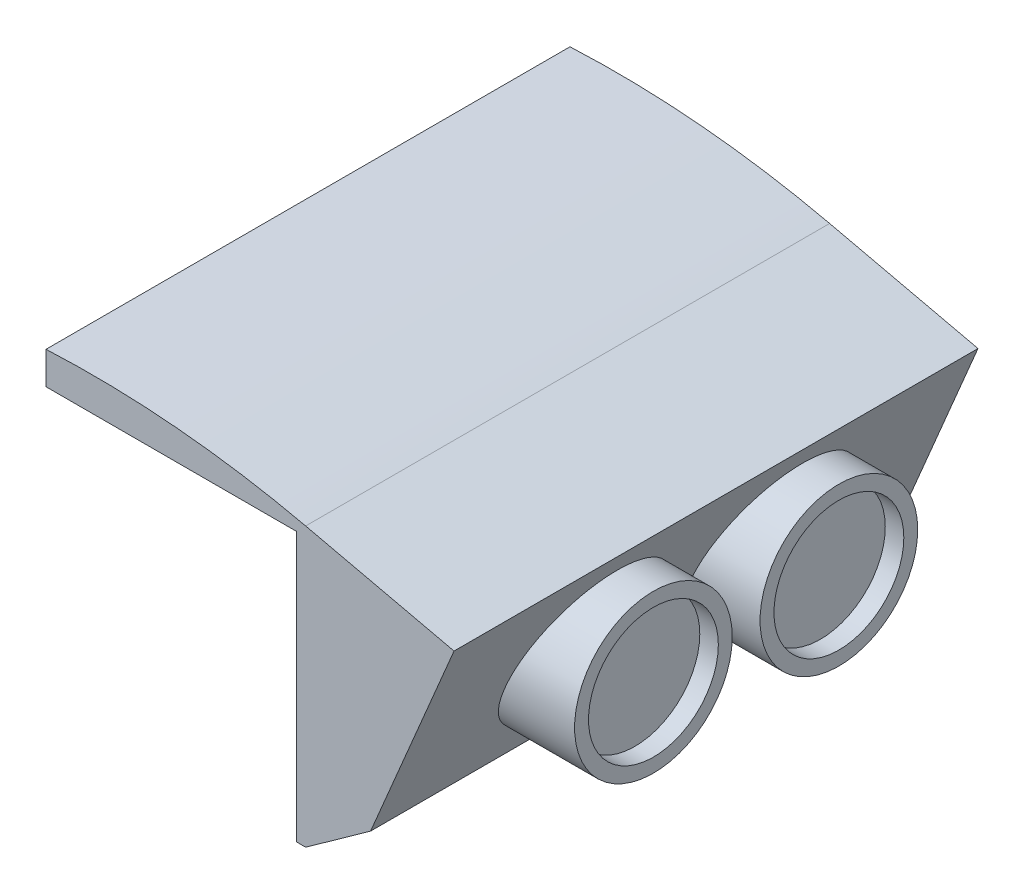
from build123d import *

# Parameters (mm, degrees)
SKETCH1_W           = 28
SKETCH1_H           = 56.5
BOSS_EXTRUDE1_DEPTH = 30
CUT_EXTRUDE2_DEPTH  = 56.5
SHELL1_T            = -1
BOSS_EXTRUDE3_DEPTH = 2.5
SKETCH4_R           = 0.35
CUT_EXTRUDE1_DEPTH  = 5
BOSS_EXTRUDE4_DEPTH = 56.5
BOSS_EXTRUDE5_START = -11.087816
SKETCH7_R           = 8.5
BOSS_EXTRUDE5_DEPTH = 11.087816
SKETCH8_R           = 7
CUT_EXTRUDE3_DEPTH  = 2
LPATTERN1_COUNT     = 2
LPATTERN1_PITCH     = 20


with BuildPart() as part:
    # Sketch1 → Boss-Extrude1 (new body)
    with BuildSketch(Plane(origin=(0, 0, 0), x_dir=(1, 0, 0), z_dir=(0, 1, 0))):
        Rectangle(SKETCH1_W, SKETCH1_H)
    extrude(amount=-BOSS_EXTRUDE1_DEPTH)

    # Sketch5 → Cut-Extrude2 (cut)
    with BuildSketch(Plane(origin=(0, 0, -28.25), x_dir=(-1, 0, 0), z_dir=(0, 0, -1))):
        with BuildLine():
            Line((-1, -30), (-1, -26))
            ThreePointArc((-1, -26), (3.188611699, -13.752551286), (14, -6.635083269))
            Line((14, -6.635083269), (14, -30))
            Line((14, -30), (-1, -30))
        make_face()
    extrude(amount=-CUT_EXTRUDE2_DEPTH, mode=Mode.SUBTRACT)

    # Shell1
    shell1_openings = [part.faces().sort_by_distance(p)[0] for p in [
        (7.5, -30, 0),
        (0.885231383, -15.011682153, 28.25),
        (-14, -3.317541634, 0),
        (-4.84430585, -15.03504646, 0),
        (1, -28, 0),
    ]]
    offset(amount=SHELL1_T, openings=shell1_openings, kind=Kind.INTERSECTION)

    # Sketch3 → Boss-Extrude3 (add, symmetric)
    with BuildSketch(Plane.XY.offset(-20)):
        with BuildLine():
            Line((-14, -1), (-15, -1))
            ThreePointArc((-15, -1), (-15.5, -1.5), (-15, -2))
            Line((-15, -2), (-14, -2))
            Line((-14, -2), (-12.5, -1))
            Line((-12.5, -1), (-14, -1))
        make_face()
    boss_extrude3 = extrude(amount=BOSS_EXTRUDE3_DEPTH, both=True)

    # Sketch4 → Cut-Extrude1 (cut)
    with BuildSketch(Plane(origin=(0, 0, -22.5), x_dir=(-1, 0, 0), z_dir=(0, 0, -1))):
        with Locations((15, -1.5)):
            Circle(SKETCH4_R)
    cut_extrude1 = extrude(amount=-CUT_EXTRUDE1_DEPTH, mode=Mode.SUBTRACT)

    # Mirror1: Boss-Extrude3, Cut-Extrude1 across plane
    add(boss_extrude3.mirror(Plane.XY))
    add(cut_extrude1.mirror(Plane.XY), mode=Mode.SUBTRACT)

    # Sketch6 → Boss-Extrude4 (add)
    with BuildSketch(Plane(origin=(0, 0, -28.25), x_dir=(-1, 0, 0), z_dir=(0, 0, -1))):
        Polygon((-30, -3.677832944), (-21, -25), (-14, -30), (-14, 0), align=None)
        with BuildLine():
            Line((14, 0), (14, 2.5))
            ThreePointArc((14, 2.5), (-0.085690207, 2.209730318), (-14, 0))
            Line((-14, 0), (14, 0))
        make_face()
    extrude(amount=-BOSS_EXTRUDE4_DEPTH)

    # Sketch7 → Boss-Extrude5 (add)
    with BuildSketch(Plane(origin=(33, 0, 0), x_dir=(0, 0, -1), z_dir=(1, 0, 0)).offset(BOSS_EXTRUDE5_START)):
        with Locations((10.25, -14.338916472)):
            Circle(SKETCH7_R)
    boss_extrude5 = extrude(amount=BOSS_EXTRUDE5_DEPTH)

    # Sketch8 → Cut-Extrude3 (cut)
    with BuildSketch(Plane(origin=(33, 0, 0), x_dir=(0, 0, -1), z_dir=(1, 0, 0))):
        with Locations((10.25, -14.338916472)):
            Circle(SKETCH8_R)
    cut_extrude3 = extrude(amount=-CUT_EXTRUDE3_DEPTH, mode=Mode.SUBTRACT)

    # LPattern1: Boss-Extrude5, Cut-Extrude3 ×2
    with Locations(*[(0, 0, i * LPATTERN1_PITCH) for i in range(1, LPATTERN1_COUNT)]):
        add(boss_extrude5)
        add(cut_extrude3, mode=Mode.SUBTRACT)


solid = part.part
